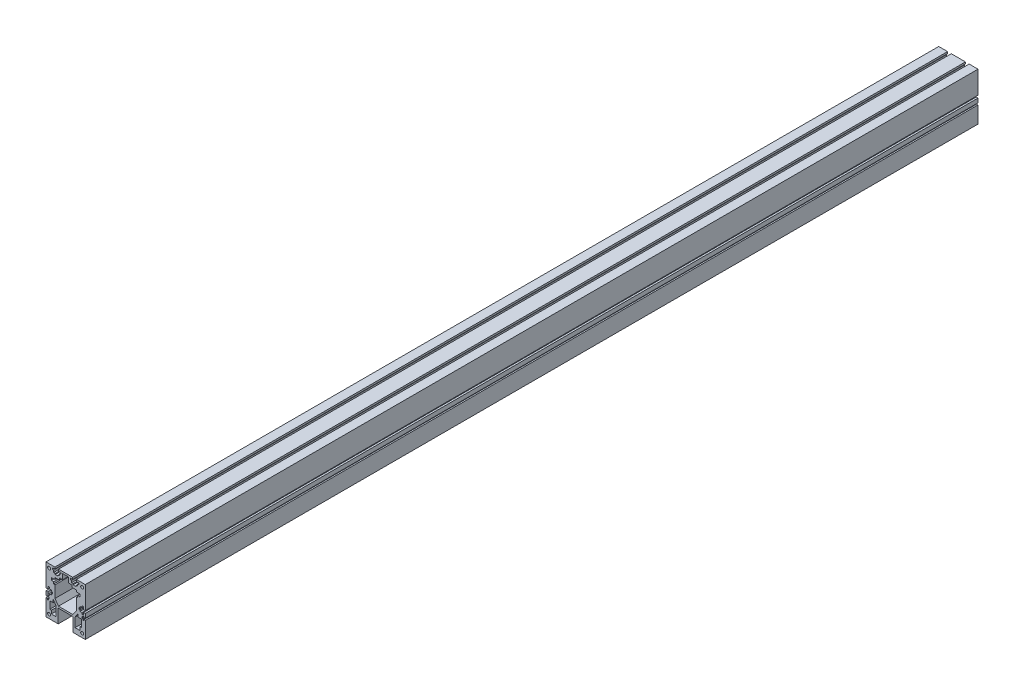
from build123d import *

# Parameters (mm, degrees)
SKETCH_2_R      = 2.5
EXTRUDE_1_DEPTH = 1500


with BuildPart() as part:
    # 草图2 → 凸台-拉伸1 (new body)
    with BuildSketch(Plane.XY):
        Polygon((-18.1, 37), (-18.1, 40), (-33, 40), (-33, 2.049564589), (-30, 2.049564589), (-30, 6.348214799), (-27.5, 6.348214799), (-27.5, 3.593219783), (-24, 3.593219783), (-24, 1.376590931), (-22.4, 1.376590931), (-22.4, -1.376590931), (-24, -1.376590931), (-24, -3.593219783), (-27.5, -3.593219783), (-27.5, -6.348214799), (-30, -6.348214799), (-30, -2.049564589), (-33, -2.049564589), (-33, -9.06837916), (-30.729793093, -9.06837916), (-30.729793093, -7.473013176), (-29.144133649, -7.473013176), (-29.144133649, -9.06837916), (-27.8, -9.06837916), (-27.8, -10.56837916), (-27.8, -12.06837916), (-29.144133649, -12.06837916), (-29.144133649, -13.663745144), (-30.729793093, -13.663745144), (-30.729793093, -12.06837916), (-33, -12.06837916), (-33, -40), (-12.5, -40), (-12.5, -17), (12.5, -17), (12.5, -40), (33, -40), (33, -12.06837916), (30.729793093, -12.06837916), (30.729793093, -13.663745144), (29.144133649, -13.663745144), (29.144133649, -12.06837916), (27.8, -12.06837916), (27.8, -10.56837916), (27.8, -9.06837916), (29.144133649, -9.06837916), (29.144133649, -7.473013176), (30.729793093, -7.473013176), (30.729793093, -9.06837916), (33, -9.06837916), (33, -2.049564589), (30, -2.049564589), (30, -6.348214799), (27.5, -6.348214799), (27.5, -3.593219783), (24, -3.593219783), (24, -1.376590931), (22.4, -1.376590931), (22.4, 1.376590931), (24, 1.376590931), (24, 3.593219783), (27.5, 3.593219783), (27.5, 6.348214799), (30, 6.348214799), (30, 2.049564589), (33, 2.049564589), (33, 40), (18.1, 40), (18.1, 37), (22.1, 37), (22.1, 34.5), (20.1, 34.5), (20.1, 31), (17.5, 31), (17.5, 29.4), (12.5, 29.4), (12.5, 31), (9.9, 31), (9.9, 34.5), (7.9, 34.5), (7.9, 37), (11.9, 37), (11.9, 40), (-11.9, 40), (-11.9, 37), (-7.9, 37), (-7.9, 34.5), (-9.9, 34.5), (-9.9, 31), (-12.5, 31), (-12.5, 29.4), (-17.5, 29.4), (-17.5, 31), (-20.1, 31), (-20.1, 34.5), (-22.1, 34.5), (-22.1, 37), align=None)
        with Locations((-27.8, -33.5)):
            Circle(SKETCH_2_R, mode=Mode.SUBTRACT)
        Polygon((-20.943121928, -13.45406673), (-20.943121928, -8.11004262), (-15.8, -15.86033199), (-15.8, -31.360910729), (-24, -31.360910729), (-24, -25.86703472), (-26.644243735, -25.86703472), (-26.644243735, -13.45406673), align=None, mode=Mode.SUBTRACT)
        with Locations((27.8, -33.5)):
            Circle(SKETCH_2_R, mode=Mode.SUBTRACT)
        Polygon((24, -25.86703472), (24, -31.360910729), (15.8, -31.360910729), (15.8, -15.86033199), (20.943121928, -8.11004262), (20.943121928, -13.45406673), (26.644243735, -13.45406673), (26.644243735, -25.86703472), align=None, mode=Mode.SUBTRACT)
        with Locations((-27.8, 33.5)):
            Circle(SKETCH_2_R, mode=Mode.SUBTRACT)
        Polygon((-24.000227571, 17.552802839), (-24.000227571, 21.788095294), (-17.932238887, 21.788095294), (-17.932238887, 24.712463894), (-10.638888278, 24.712463894), (-10.638888278, 28.169211595), (-4.9, 28.169211595), (-4.9, 37), (4.9, 37), (4.9, 28.169211595), (10.638888278, 28.169211595), (10.638888278, 24.712463894), (17.932238887, 24.712463894), (17.932238887, 21.788095294), (24.000227571, 21.788095294), (24.000227571, 17.552802839), (20.143121928, 17.552802839), (20.143121928, 14.174652905), (17.932238887, 14.174652905), (17.932238887, -5.752091446), (12.045824189, -14), (0, -14), (-12.045824189, -14), (-17.932238887, -5.752091446), (-17.932238887, 14.174652905), (-20.143121928, 14.174652905), (-20.143121928, 17.552802839), align=None, mode=Mode.SUBTRACT)
        with Locations((27.8, 33.5)):
            Circle(SKETCH_2_R, mode=Mode.SUBTRACT)
    extrude(amount=EXTRUDE_1_DEPTH)


solid = part.part
